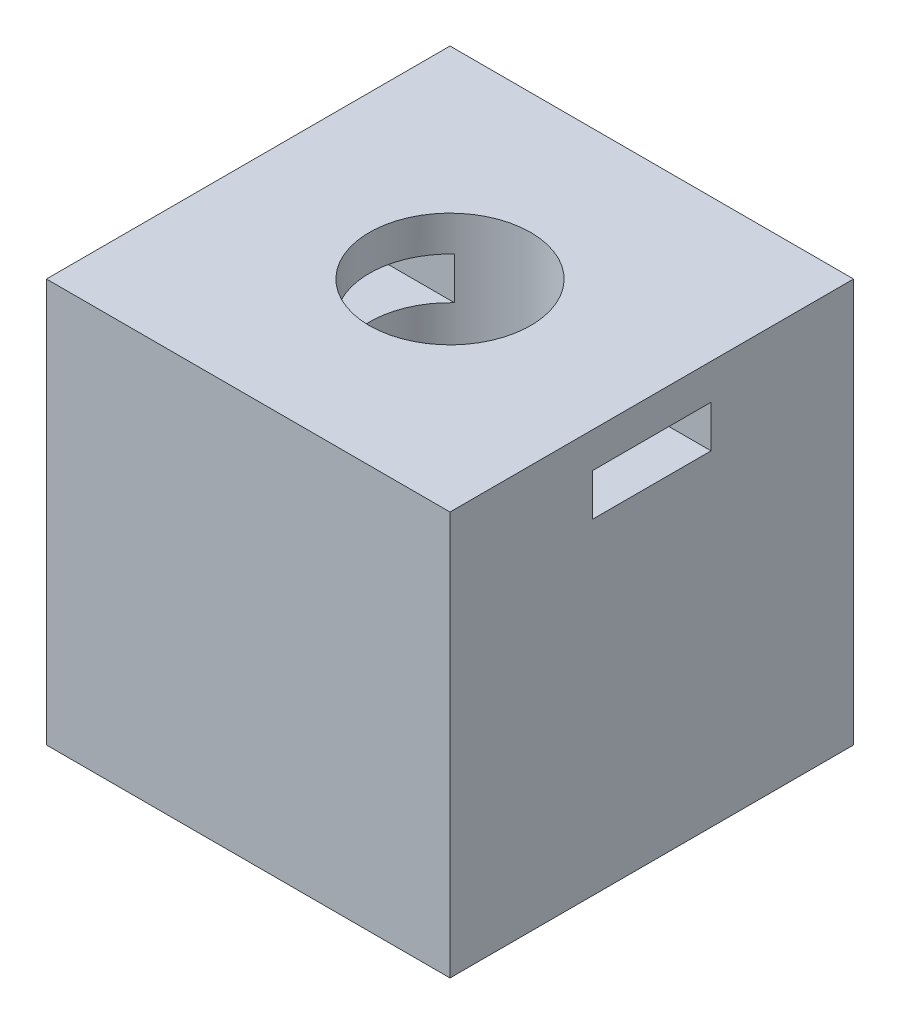
from build123d import *

# Parameters (mm, degrees)
ESQUISSE1_W             = 15
ESQUISSE1_H             = 15
ESQUISSE1_R             = 3
BOSS_EXTRU_1_DEPTH      = 15
ESQUISSE2_W             = 4.404326356
ESQUISSE2_H             = 1.565605919
ENL_V_MAT_EXTRU_1_DEPTH = 15
ESQUISSE3_R             = 1.5
ENL_V_MAT_EXTRU_2_DEPTH = 10


with BuildPart() as part:
    # Esquisse1 → Boss.-Extru.1 (new body)
    with BuildSketch(Plane(origin=(0, 0, 0), x_dir=(1, 0, 0), z_dir=(0, 1, 0))):
        Rectangle(ESQUISSE1_W, ESQUISSE1_H)
        Circle(ESQUISSE1_R, mode=Mode.SUBTRACT)
    extrude(amount=BOSS_EXTRU_1_DEPTH)

    # Esquisse2 → Enlèv. mat.-Extru.1 (cut)
    with BuildSketch(Plane(origin=(7.5, 0, 0), x_dir=(0, 0, -1), z_dir=(1, 0, 0))):
        with Locations((0, 12.899904082)):
            Rectangle(ESQUISSE2_W, ESQUISSE2_H)
    extrude(amount=-ENL_V_MAT_EXTRU_1_DEPTH, mode=Mode.SUBTRACT)

    # Esquisse3 → Enlèv. mat.-Extru.2 (cut)
    with BuildSketch(Plane.XZ):
        with Locations((5, 0)):
            Circle(ESQUISSE3_R)
        with Locations((-5, 0)):
            Circle(ESQUISSE3_R)
    extrude(amount=-ENL_V_MAT_EXTRU_2_DEPTH, mode=Mode.SUBTRACT)


solid = part.part
